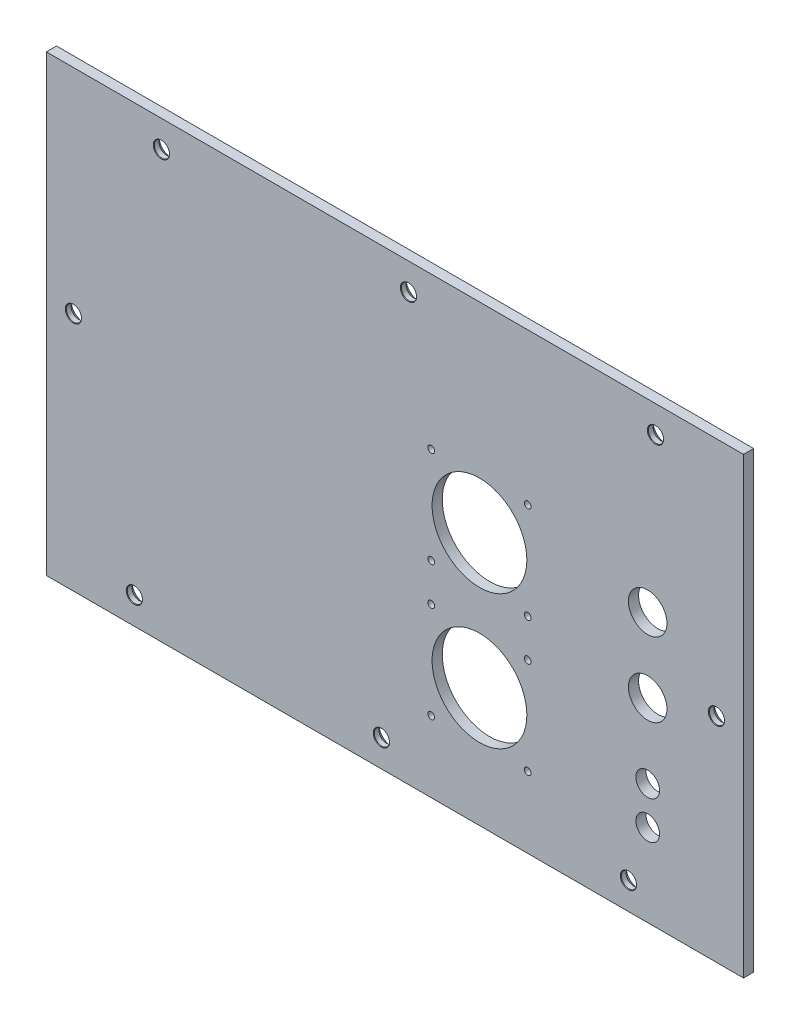
from build123d import *

# Parameters (mm, degrees)
SKETCH_1_W                 = 206
SKETCH_1_H                 = 134
SKETCH_1_R                 = 14
SKETCH_1_R_2               = 3.5
SKETCH_1_R_3               = 5.7
SKETCH_1_R_4               = 1
EXTRUDE_1_DEPTH            = 3
HOLE_WIZARD_M41_AT_2_COUNT = 2
HOLE_WIZARD_M41_AT_2_PITCH = 73
HOLE_WIZARD_M41_AT_3_COUNT = 2
HOLE_WIZARD_M41_AT_3_PITCH = 146
HOLE_WIZARD_M41_AT_4_COUNT = 2
HOLE_WIZARD_M41_AT_4_PITCH = 180.579622328
HOLE_WIZARD_M41_AT_5_COUNT = 2
HOLE_WIZARD_M41_AT_5_PITCH = 194.010309004
HOLE_WIZARD_M41_AT_6_COUNT = 2
HOLE_WIZARD_M41_AT_6_PITCH = 143.125818775
HOLE_WIZARD_M41_AT_7_COUNT = 2
HOLE_WIZARD_M41_AT_7_PITCH = 118.270875536
HOLE_WIZARD_M41_AT_8_COUNT = 2
HOLE_WIZARD_M41_AT_8_PITCH = 65.520989004


with BuildPart() as part:
    # Эскиз1 → Бобышка-Вытянуть1 (new body)
    with BuildSketch(Plane.XY):
        with Locations((103, 67)):
            Rectangle(SKETCH_1_W, SKETCH_1_H)
        with Locations((127.983323234, 74.939626383)):
            Circle(SKETCH_1_R, mode=Mode.SUBTRACT)
        with Locations((127.983323234, 35.24984102)):
            Circle(SKETCH_1_R, mode=Mode.SUBTRACT)
        with Locations((177.691125973, 35.560610723)):
            Circle(SKETCH_1_R_2, mode=Mode.SUBTRACT)
        with Locations((177.691125973, 24.371028973)):
            Circle(SKETCH_1_R_2, mode=Mode.SUBTRACT)
        with Locations((177.691125973, 79.434554566)):
            Circle(SKETCH_1_R_3, mode=Mode.SUBTRACT)
        with Locations((177.691125973, 57.509564132)):
            Circle(SKETCH_1_R_3, mode=Mode.SUBTRACT)
        with Locations((113.733323234, 89.189626383)):
            Circle(SKETCH_1_R_4, mode=Mode.SUBTRACT)
        with Locations((142.233323234, 89.189626383)):
            Circle(SKETCH_1_R_4, mode=Mode.SUBTRACT)
        with Locations((113.733323234, 49.49984102)):
            Circle(SKETCH_1_R_4, mode=Mode.SUBTRACT)
        with Locations((142.233323234, 49.49984102)):
            Circle(SKETCH_1_R_4, mode=Mode.SUBTRACT)
        with Locations((142.233323234, 20.99984102)):
            Circle(SKETCH_1_R_4, mode=Mode.SUBTRACT)
        with Locations((113.733323234, 20.99984102)):
            Circle(SKETCH_1_R_4, mode=Mode.SUBTRACT)
        with Locations((142.233323234, 60.689626383)):
            Circle(SKETCH_1_R_4, mode=Mode.SUBTRACT)
        with Locations((113.733323234, 60.689626383)):
            Circle(SKETCH_1_R_4, mode=Mode.SUBTRACT)
    extrude(amount=EXTRUDE_1_DEPTH)

    # Эскиз2 → Зенковка для винта с потайной головкой M41 (revolve, cut)
    with BuildSketch(Plane(origin=(26, 8, 0), x_dir=(0, 1, 0), z_dir=(1, 0, 0))):
        Polygon((0, 0), (0, 3), (2.4, 3), (2.25, 2.85), (2.25, 1.45), (3.7, 0), align=None)
    hole_wizard_m41 = revolve(axis=Axis((26, 8, -6.35), (0, 0, 1)), mode=Mode.SUBTRACT)

    # Зенковка для винта с потайной головкой M41 at 2: Зенковка для винта с потайной головкой M41 ×2
    with Locations(*[(i * HOLE_WIZARD_M41_AT_2_PITCH, 0, 0) for i in range(1, HOLE_WIZARD_M41_AT_2_COUNT)]):
        add(hole_wizard_m41, mode=Mode.SUBTRACT)

    # Зенковка для винта с потайной головкой M41 at 3: Зенковка для винта с потайной головкой M41 ×2
    with Locations(*[(i * HOLE_WIZARD_M41_AT_3_PITCH, 0, 0) for i in range(1, HOLE_WIZARD_M41_AT_3_COUNT)]):
        add(hole_wizard_m41, mode=Mode.SUBTRACT)

    # Зенковка для винта с потайной головкой M41 at 4: Зенковка для винта с потайной головкой M41 ×2
    with Locations(*[Vector(0.952488425, 0.304574787, 0) * (i * HOLE_WIZARD_M41_AT_4_PITCH) for i in range(1, HOLE_WIZARD_M41_AT_4_COUNT)]):
        add(hole_wizard_m41, mode=Mode.SUBTRACT)

    # Зенковка для винта с потайной головкой M41 at 5: Зенковка для винта с потайной головкой M41 ×2
    with Locations(*[Vector(0.793772253, 0.608215103, 0) * (i * HOLE_WIZARD_M41_AT_5_PITCH) for i in range(1, HOLE_WIZARD_M41_AT_5_COUNT)]):
        add(hole_wizard_m41, mode=Mode.SUBTRACT)

    # Зенковка для винта с потайной головкой M41 at 6: Зенковка для винта с потайной головкой M41 ×2
    with Locations(*[Vector(0.565935627, 0.824449432, 0) * (i * HOLE_WIZARD_M41_AT_6_PITCH) for i in range(1, HOLE_WIZARD_M41_AT_6_COUNT)]):
        add(hole_wizard_m41, mode=Mode.SUBTRACT)

    # Зенковка для винта с потайной головкой M41 at 7: Зенковка для винта с потайной головкой M41 ×2
    with Locations(*[Vector(0.067641336, 0.997709702, 0) * (i * HOLE_WIZARD_M41_AT_7_PITCH) for i in range(1, HOLE_WIZARD_M41_AT_7_COUNT)]):
        add(hole_wizard_m41, mode=Mode.SUBTRACT)

    # Зенковка для винта с потайной головкой M41 at 8: Зенковка для винта с потайной головкой M41 ×2
    with Locations(*[Vector(-0.274721128, 0.961523948, 0) * (i * HOLE_WIZARD_M41_AT_8_PITCH) for i in range(1, HOLE_WIZARD_M41_AT_8_COUNT)]):
        add(hole_wizard_m41, mode=Mode.SUBTRACT)


solid = part.part
